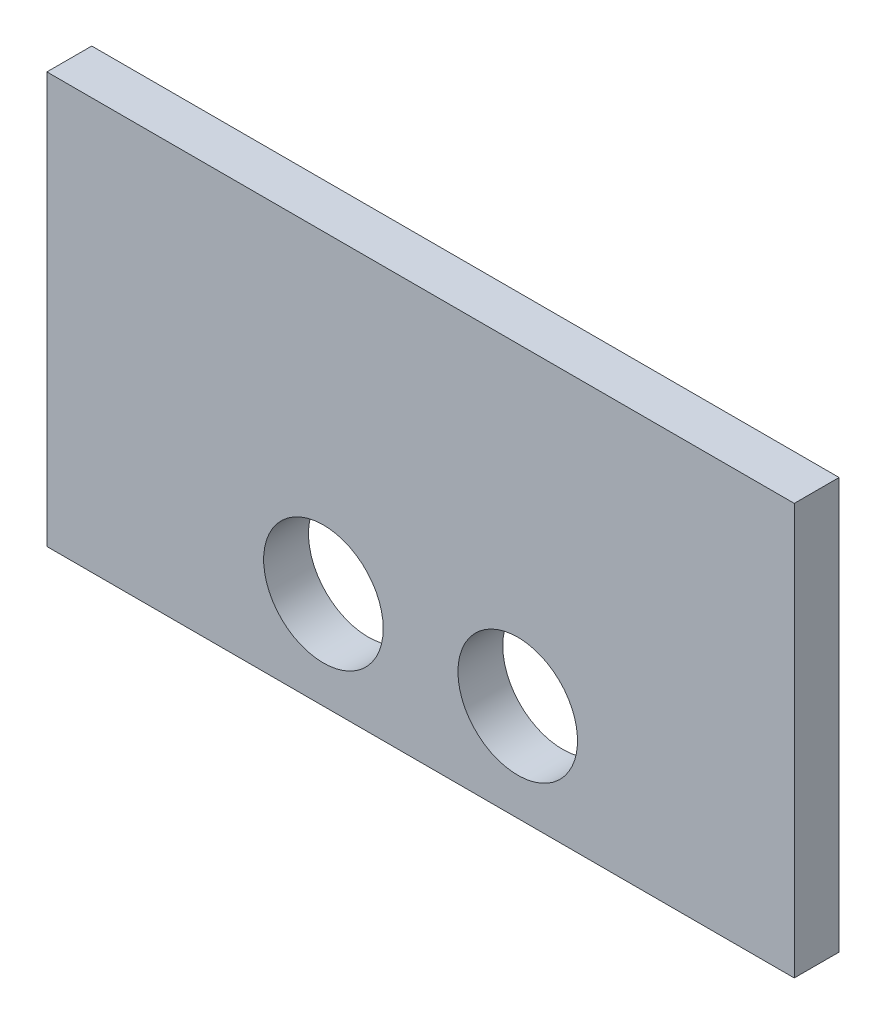
from build123d import *

# Parameters (mm, degrees)
SKETCH1_W           = 100
SKETCH1_H           = 55
BOSS_EXTRUDE1_DEPTH = 6
SKETCH2_R           = 8
CUT_EXTRUDE1_DEPTH  = 6


with BuildPart() as part:
    # Sketch1 → Boss-Extrude1 (new body)
    with BuildSketch(Plane.XY):
        with Locations((0, 18.901219808)):
            Rectangle(SKETCH1_W, SKETCH1_H)
    extrude(amount=BOSS_EXTRUDE1_DEPTH)

    # Sketch2 → Cut-Extrude1 (cut)
    with BuildSketch(Plane.XY.offset(6)):
        with Locations((-13, 4.401219808)):
            Circle(SKETCH2_R)
        with Locations((13, 4.401219808)):
            Circle(SKETCH2_R)
    extrude(amount=-CUT_EXTRUDE1_DEPTH, mode=Mode.SUBTRACT)


solid = part.part
